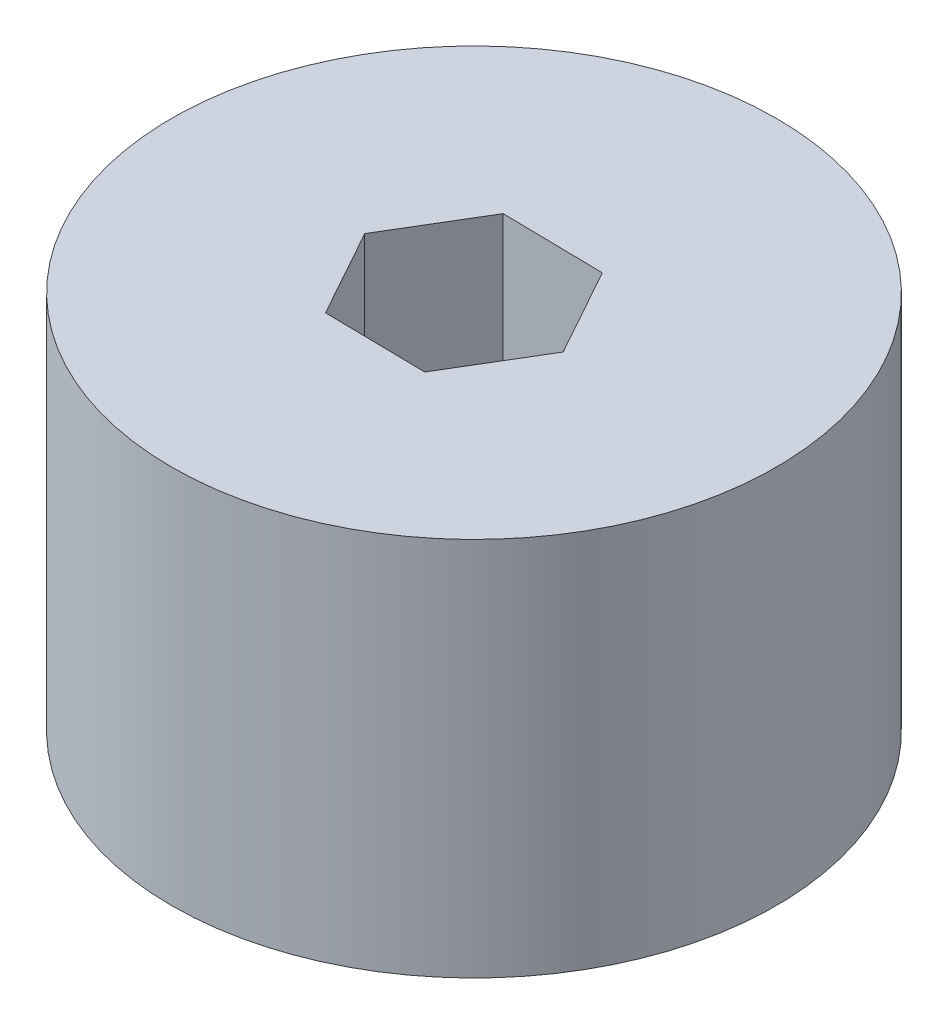
from build123d import *

# Parameters (mm, degrees)
SKETCH1_R           = 20.209977283
BOSS_EXTRUDE1_DEPTH = 25.4


with BuildPart() as part:
    # Sketch1 → Boss-Extrude1 (new body)
    with BuildSketch(Plane(origin=(0, 0, 0), x_dir=(1, 0, 0), z_dir=(0, 1, 0))):
        Circle(SKETCH1_R)
        Polygon((2.945492592, -6.239639902), (6.414550483, -0.453674858), (3.138286715, 5.443599925), (-3.607034944, 5.554909663), (-7.076092835, -0.231055381), (-3.799829067, -6.128330163), align=None, mode=Mode.SUBTRACT)
    extrude(amount=BOSS_EXTRUDE1_DEPTH)


solid = part.part
